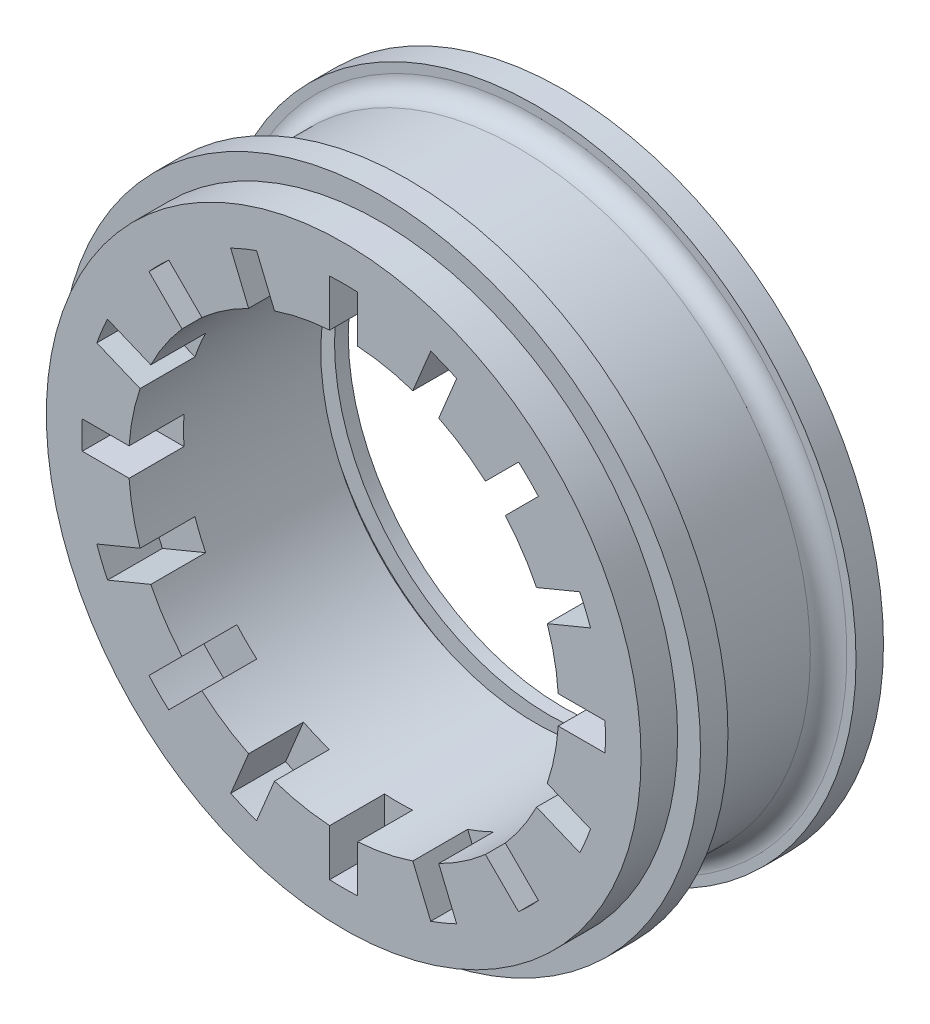
from build123d import *

# Parameters (mm, degrees)
SKETCH_1_R          = 35
SKETCH_1_R_2        = 25
SKETCH_1_R_3        = 23.5
EXTRUDE_1_DEPTH     = 10
SKETCH_3_R          = 32.5
SKETCH_3_R_2        = 23.5
EXTRUDE_2_DEPTH     = 4
CUT_EXTRUDE_1_DEPTH = 6
SKETCH_7_W          = 1.5
SKETCH_7_H          = 2


with BuildPart() as part:
    # 草图1 → 凸台-拉伸1 (new, symmetric)
    with BuildSketch(Plane.XY):
        Circle(SKETCH_1_R)
        Circle(SKETCH_1_R_2, mode=Mode.SUBTRACT)
        Circle(SKETCH_1_R_2)
        Circle(SKETCH_1_R_3, mode=Mode.SUBTRACT)
    extrude(amount=EXTRUDE_1_DEPTH, both=True)

    # 草图2 → 切除-旋转1 (revolve, cut)
    with BuildSketch(Plane(origin=(0, 0, 0), x_dir=(0, 0, -1), z_dir=(1, 0, 0)), mode=Mode.PRIVATE) as cut_revolve_1_sk:
        with BuildLine():
            Line((-7, 40), (-7, 34))
            ThreePointArc((-7, 34), (-6.414213562, 32.585786438), (-5, 32))
            Line((-5, 32), (5, 32))
            ThreePointArc((5, 32), (6.414213562, 32.585786438), (7, 34))
            Line((7, 34), (7, 40))
            Line((7, 40), (-7, 40))
        make_face()
    revolve(cut_revolve_1_sk.sketch.rotate(Axis((0, 0, 0), (0, 0, 1)), 90), axis=Axis((0, 0, 0), (0, 0, 1)), mode=Mode.SUBTRACT)

    # 草图3 → 凸台-拉伸2 (add)
    with BuildSketch(Plane.XY.offset(10)):
        Circle(SKETCH_3_R)
        Circle(SKETCH_3_R_2, mode=Mode.SUBTRACT)
    extrude(amount=EXTRUDE_2_DEPTH)

    # 草图5 → 切除-拉伸1 (cut)
    with BuildSketch(Plane.XY.offset(14)):
        with BuildLine():
            ThreePointArc((19.116635677, -21.28407168), (20.229402697, -20.229402697), (21.28407168, -19.116635677))
            Line((21.28407168, -19.116635677), (19.498162716, -17.330726713))
            Line((19.498162716, -17.330726713), (17.665351072, -15.497915069))
            ThreePointArc((17.665351072, -15.497915069), (16.623496591, -16.610519591), (15.511706041, -17.65324264))
            ThreePointArc((15.511706041, -17.65324264), (15.504811737, -17.659298202), (15.497915069, -17.665351072))
            Line((15.497915069, -17.665351072), (17.330726713, -19.498162716))
            Line((17.330726713, -19.498162716), (19.116635677, -21.28407168))
        make_face()
        with BuildLine():
            ThreePointArc((25.806530038, -12.348298438), (26.430988365, -10.948073848), (26.97953795, -9.516406827))
            Line((26.97953795, -9.516406827), (24.646135439, -8.549879861))
            Line((24.646135439, -8.549879861), (22.251451624, -7.557969347))
            ThreePointArc((22.251451624, -7.557969347), (21.71467891, -8.984582342), (21.086551211, -10.373396648))
            ThreePointArc((21.086551211, -10.373396648), (21.082499068, -10.381629594), (21.078443711, -10.389860957))
            Line((21.078443711, -10.389860957), (23.473127527, -11.381771471))
            Line((23.473127527, -11.381771471), (25.806530038, -12.348298438))
        make_face()
        with BuildLine():
            ThreePointArc((28.567614137, -1.532608696), (28.608695652, 0), (28.567614137, 1.532608696))
            Line((28.567614137, 1.532608696), (26.041957459, 1.532608696))
            Line((26.041957459, 1.532608696), (23.449970375, 1.532608696))
            ThreePointArc((23.449970375, 1.532608696), (23.487489264, 0.766712524), (23.5, 0))
            ThreePointArc((23.5, 0), (23.487786854, -0.757541226), (23.45116011, -1.514295052))
            ThreePointArc((23.45116011, -1.514295052), (23.45056703, -1.52345199), (23.449970375, -1.532608696))
            Line((23.449970375, -1.532608696), (26.041957459, -1.532608696))
            Line((26.041957459, -1.532608696), (28.567614137, -1.532608696))
        make_face()
        with BuildLine():
            ThreePointArc((26.97953795, 9.516406827), (26.430988365, 10.948073848), (25.806530038, 12.348298438))
            Line((25.806530038, 12.348298438), (23.473127527, 11.381771471))
            Line((23.473127527, 11.381771471), (21.078443711, 10.389860957))
            ThreePointArc((21.078443711, 10.389860957), (21.707655808, 9.001537608), (22.245542467, 7.575344239))
            ThreePointArc((22.245542467, 7.575344239), (22.248498741, 7.56665737), (22.251451624, 7.557969347))
            Line((22.251451624, 7.557969347), (24.646135439, 8.549879861))
            Line((24.646135439, 8.549879861), (26.97953795, 9.516406827))
        make_face()
        with BuildLine():
            ThreePointArc((21.28407168, 19.116635677), (20.229402697, 20.229402697), (19.116635677, 21.28407168))
            Line((19.116635677, 21.28407168), (17.330726713, 19.498162716))
            Line((17.330726713, 19.498162716), (15.497915069, 17.665351072))
            ThreePointArc((15.497915069, 17.665351072), (16.610519591, 16.623496591), (17.65324264, 15.511706041))
            ThreePointArc((17.65324264, 15.511706041), (17.659298202, 15.504811737), (17.665351072, 15.497915069))
            Line((17.665351072, 15.497915069), (19.498162716, 17.330726713))
            Line((19.498162716, 17.330726713), (21.28407168, 19.116635677))
        make_face()
        with BuildLine():
            Line((9.516406827, 26.97953795), (8.549879861, 24.646135439))
            Line((8.549879861, 24.646135439), (7.557969347, 22.251451624))
            ThreePointArc((7.557969347, 22.251451624), (8.984582342, 21.71467891), (10.373396648, 21.086551211))
            ThreePointArc((10.373396648, 21.086551211), (10.381629594, 21.082499068), (10.389860957, 21.078443711))
            Line((10.389860957, 21.078443711), (11.381771471, 23.473127527))
            Line((11.381771471, 23.473127527), (12.348298438, 25.806530038))
            ThreePointArc((12.348298438, 25.806530038), (10.948073848, 26.430988365), (9.516406827, 26.97953795))
        make_face()
        with BuildLine():
            ThreePointArc((1.514295052, 23.45116011), (1.52345199, 23.45056703), (1.532608696, 23.449970375))
            Line((1.532608696, 23.449970375), (1.532608696, 26.041957459))
            Line((1.532608696, 26.041957459), (1.532608696, 28.567614137))
            ThreePointArc((1.532608696, 28.567614137), (0, 28.608695652), (-1.532608696, 28.567614137))
            Line((-1.532608696, 28.567614137), (-1.532608696, 26.041957459))
            Line((-1.532608696, 26.041957459), (-1.532608696, 23.449970375))
            ThreePointArc((-1.532608696, 23.449970375), (-0.009176124, 23.499998208), (1.514295052, 23.45116011))
        make_face()
        with BuildLine():
            ThreePointArc((9.516406827, -26.97953795), (10.948073848, -26.430988365), (12.348298438, -25.806530038))
            Line((12.348298438, -25.806530038), (11.381771471, -23.473127527))
            Line((11.381771471, -23.473127527), (10.389860957, -21.078443711))
            ThreePointArc((10.389860957, -21.078443711), (9.001537608, -21.707655808), (7.575344239, -22.245542467))
            ThreePointArc((7.575344239, -22.245542467), (7.56665737, -22.248498741), (7.557969347, -22.251451624))
            Line((7.557969347, -22.251451624), (8.549879861, -24.646135439))
            Line((8.549879861, -24.646135439), (9.516406827, -26.97953795))
        make_face()
        with BuildLine():
            ThreePointArc((-1.532608696, -28.567614137), (0, -28.608695652), (1.532608696, -28.567614137))
            Line((1.532608696, -28.567614137), (1.532608696, -26.041957459))
            Line((1.532608696, -26.041957459), (1.532608696, -23.449970375))
            ThreePointArc((1.532608696, -23.449970375), (0.009176124, -23.499998208), (-1.514295052, -23.45116011))
            ThreePointArc((-1.514295052, -23.45116011), (-1.52345199, -23.45056703), (-1.532608696, -23.449970375))
            Line((-1.532608696, -23.449970375), (-1.532608696, -26.041957459))
            Line((-1.532608696, -26.041957459), (-1.532608696, -28.567614137))
        make_face()
        with BuildLine():
            Line((-11.381771471, -23.473127527), (-12.348298438, -25.806530038))
            ThreePointArc((-12.348298438, -25.806530038), (-10.948073848, -26.430988365), (-9.516406827, -26.97953795))
            Line((-9.516406827, -26.97953795), (-8.549879861, -24.646135439))
            Line((-8.549879861, -24.646135439), (-7.557969347, -22.251451624))
            ThreePointArc((-7.557969347, -22.251451624), (-8.984582342, -21.71467891), (-10.373396648, -21.086551211))
            ThreePointArc((-10.373396648, -21.086551211), (-10.381629594, -21.082499068), (-10.389860957, -21.078443711))
            Line((-10.389860957, -21.078443711), (-11.381771471, -23.473127527))
        make_face()
        with BuildLine():
            Line((-19.498162716, -17.330726713), (-21.28407168, -19.116635677))
            ThreePointArc((-21.28407168, -19.116635677), (-20.229402697, -20.229402697), (-19.116635677, -21.28407168))
            Line((-19.116635677, -21.28407168), (-17.330726713, -19.498162716))
            Line((-17.330726713, -19.498162716), (-15.497915069, -17.665351072))
            ThreePointArc((-15.497915069, -17.665351072), (-16.610519591, -16.623496591), (-17.65324264, -15.511706041))
            ThreePointArc((-17.65324264, -15.511706041), (-17.659298202, -15.504811737), (-17.665351072, -15.497915069))
            Line((-17.665351072, -15.497915069), (-19.498162716, -17.330726713))
        make_face()
        with BuildLine():
            Line((-24.646135439, -8.549879861), (-26.97953795, -9.516406827))
            ThreePointArc((-26.97953795, -9.516406827), (-26.430988365, -10.948073848), (-25.806530038, -12.348298438))
            Line((-25.806530038, -12.348298438), (-23.473127527, -11.381771471))
            Line((-23.473127527, -11.381771471), (-21.078443711, -10.389860957))
            ThreePointArc((-21.078443711, -10.389860957), (-21.707655808, -9.001537608), (-22.245542467, -7.575344239))
            ThreePointArc((-22.245542467, -7.575344239), (-22.248498741, -7.56665737), (-22.251451624, -7.557969347))
            Line((-22.251451624, -7.557969347), (-24.646135439, -8.549879861))
        make_face()
        with BuildLine():
            Line((-26.041957459, 1.532608696), (-28.567614137, 1.532608696))
            ThreePointArc((-28.567614137, 1.532608696), (-28.608695652, 0), (-28.567614137, -1.532608696))
            Line((-28.567614137, -1.532608696), (-26.041957459, -1.532608696))
            Line((-26.041957459, -1.532608696), (-23.449970375, -1.532608696))
            ThreePointArc((-23.449970375, -1.532608696), (-23.499998208, -0.009176124), (-23.45116011, 1.514295052))
            ThreePointArc((-23.45116011, 1.514295052), (-23.45056703, 1.52345199), (-23.449970375, 1.532608696))
            Line((-23.449970375, 1.532608696), (-26.041957459, 1.532608696))
        make_face()
        with BuildLine():
            Line((-23.473127527, 11.381771471), (-25.806530038, 12.348298438))
            ThreePointArc((-25.806530038, 12.348298438), (-26.430988365, 10.948073848), (-26.97953795, 9.516406827))
            Line((-26.97953795, 9.516406827), (-24.646135439, 8.549879861))
            Line((-24.646135439, 8.549879861), (-22.251451624, 7.557969347))
            ThreePointArc((-22.251451624, 7.557969347), (-21.71467891, 8.984582342), (-21.086551211, 10.373396648))
            ThreePointArc((-21.086551211, 10.373396648), (-21.082499068, 10.381629594), (-21.078443711, 10.389860957))
            Line((-21.078443711, 10.389860957), (-23.473127527, 11.381771471))
        make_face()
        with BuildLine():
            Line((-17.330726713, 19.498162716), (-19.116635677, 21.28407168))
            ThreePointArc((-19.116635677, 21.28407168), (-20.229402697, 20.229402697), (-21.28407168, 19.116635677))
            Line((-21.28407168, 19.116635677), (-19.498162716, 17.330726713))
            Line((-19.498162716, 17.330726713), (-17.665351072, 15.497915069))
            ThreePointArc((-17.665351072, 15.497915069), (-16.623496591, 16.610519591), (-15.511706041, 17.65324264))
            ThreePointArc((-15.511706041, 17.65324264), (-15.504811737, 17.659298202), (-15.497915069, 17.665351072))
            Line((-15.497915069, 17.665351072), (-17.330726713, 19.498162716))
        make_face()
        with BuildLine():
            Line((-8.549879861, 24.646135439), (-9.516406827, 26.97953795))
            ThreePointArc((-9.516406827, 26.97953795), (-10.948073848, 26.430988365), (-12.348298438, 25.806530038))
            Line((-12.348298438, 25.806530038), (-11.381771471, 23.473127527))
            Line((-11.381771471, 23.473127527), (-10.389860957, 21.078443711))
            ThreePointArc((-10.389860957, 21.078443711), (-9.001537608, 21.707655808), (-7.575344239, 22.245542467))
            ThreePointArc((-7.575344239, 22.245542467), (-7.56665737, 22.248498741), (-7.557969347, 22.251451624))
            Line((-7.557969347, 22.251451624), (-8.549879861, 24.646135439))
        make_face()
    extrude(amount=-CUT_EXTRUDE_1_DEPTH, mode=Mode.SUBTRACT)

    # 草图7 → 切除-旋转2 (revolve, cut)
    with BuildSketch(Plane(origin=(0, 0, 0), x_dir=(0, 0, -1), z_dir=(1, 0, 0)), mode=Mode.PRIVATE) as cut_revolve_2_sk:
        with Locations((7.75, 24.5)):
            Rectangle(SKETCH_7_W, SKETCH_7_H)
    revolve(cut_revolve_2_sk.sketch.rotate(Axis((0, 0, 0), (0, 0, -1)), 266.260664768), axis=Axis((0, 0, 0), (0, 0, -1)), mode=Mode.SUBTRACT)


solid = part.part
